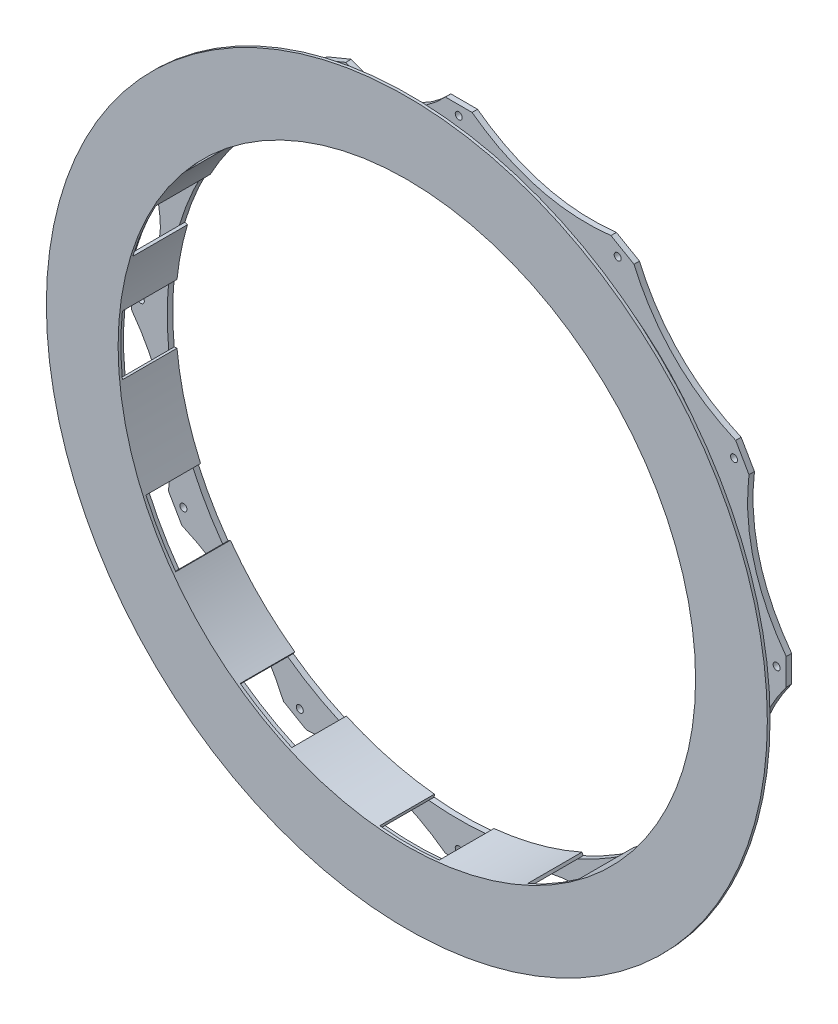
from build123d import *
from build123d.topology import SkipClean

# Parameters (mm, degrees)
SKETCH4_R           = 169.4688
SKETCH4_R_2         = 2.032
BOSS_EXTRUDE1_DEPTH = 3.175
SKETCH5_R           = 169.4688
SKETCH5_R_2         = 2.032
BOSS_EXTRUDE2_DEPTH = 3.175
BOSS_EXTRUDE3_DEPTH = 31.75
SKETCH7_R           = 209.55
SKETCH7_R_2         = 167.8432
BOSS_EXTRUDE4_DEPTH = 1.5875


with BuildPart() as part:
    # Sketch4 → Boss-Extrude1 (new body)
    with BuildSketch(Plane.XY):
        with BuildLine():
            Line((-7.735342369, 190.342886598), (7.735342369, 190.342886598))
            add(Edge.make_bspline(
                [(7.735342369, 190.342886598), (43.849986057, 163.650375876), (88.472440301, 168.709446408)],
                knots=[0, 0, 0, 1, 1, 1], degree=2))
            Line((88.472440301, 168.709446408), (101.870446297, 160.974104039))
            add(Edge.make_bspline(
                [(101.870446297, 160.974104039), (119.800389819, 119.800389819), (160.974104039, 101.870446297)],
                knots=[0, 0, 0, 1, 1, 1], degree=2))
            Line((160.974104039, 101.870446297), (168.709446408, 88.472440301))
            add(Edge.make_bspline(
                [(168.709446408, 88.472440301), (163.650375876, 43.849986057), (190.342886598, 7.735342369)],
                knots=[0, 0, 0, 1, 1, 1], degree=2))
            Line((190.342886598, 7.735342369), (190.342886598, -7.735342369))
            add(Edge.make_bspline(
                [(190.342886598, -7.735342369), (163.650375876, -43.849986057), (168.709446408, -88.472440301)],
                knots=[0, 0, 0, 1, 1, 1], degree=2))
            Line((168.709446408, -88.472440301), (160.974104039, -101.870446297))
            add(Edge.make_bspline(
                [(160.974104039, -101.870446297), (119.800389819, -119.800389819), (101.870446297, -160.974104039)],
                knots=[0, 0, 0, 1, 1, 1], degree=2))
            Line((101.870446297, -160.974104039), (88.472440301, -168.709446408))
            add(Edge.make_bspline(
                [(88.472440301, -168.709446408), (43.849986057, -163.650375876), (7.735342369, -190.342886598)],
                knots=[0, 0, 0, 1, 1, 1], degree=2))
            Line((7.735342369, -190.342886598), (-7.735342369, -190.342886598))
            add(Edge.make_bspline(
                [(-7.735342369, -190.342886598), (-43.849986057, -163.650375876), (-88.472440301, -168.709446408)],
                knots=[0, 0, 0, 1, 1, 1], degree=2))
            Line((-88.472440301, -168.709446408), (-101.870446297, -160.974104039))
            add(Edge.make_bspline(
                [(-101.870446297, -160.974104039), (-119.800389819, -119.800389819), (-160.974104039, -101.870446297)],
                knots=[0, 0, 0, 1, 1, 1], degree=2))
            Line((-160.974104039, -101.870446297), (-168.709446408, -88.472440301))
            add(Edge.make_bspline(
                [(-168.709446408, -88.472440301), (-163.650375876, -43.849986057), (-190.342886598, -7.735342369)],
                knots=[0, 0, 0, 1, 1, 1], degree=2))
            Line((-190.342886598, -7.735342369), (-190.342886598, 7.735342369))
            add(Edge.make_bspline(
                [(-190.342886598, 7.735342369), (-163.877360858, 32.597233808), (-178.814084455, 65.694544678)],
                knots=[0, 0, 0, 1, 1, 1], degree=2))
            Line((-178.814084455, 65.694544678), (-172.893709719, 79.987593661))
            add(Edge.make_bspline(
                [(-172.893709719, 79.987593661), (-138.92851822, 92.829068072), (-140.062458908, 129.12303282)],
                knots=[0, 0, 0, 1, 1, 1], degree=2))
            Line((-140.062458908, 129.12303282), (-129.12303282, 140.062458908))
            add(Edge.make_bspline(
                [(-129.12303282, 140.062458908), (-92.829068072, 138.92851822), (-79.987593661, 172.893709719)],
                knots=[0, 0, 0, 1, 1, 1], degree=2))
            Line((-79.987593661, 172.893709719), (-65.694544678, 178.814084455))
            add(Edge.make_bspline(
                [(-65.694544678, 178.814084455), (-32.597233808, 163.877360858), (-7.735342369, 190.342886598)],
                knots=[0, 0, 0, 1, 1, 1], degree=2))
        make_face()
        Circle(SKETCH4_R, mode=Mode.SUBTRACT)
        with Locations((0, 184.785)):
            Circle(SKETCH4_R_2, mode=Mode.SUBTRACT)
        with Locations((-160.028504238, -92.3925)):
            Circle(SKETCH4_R_2, mode=Mode.SUBTRACT)
        with Locations((-92.3925, -160.028504238)):
            Circle(SKETCH4_R_2, mode=Mode.SUBTRACT)
        with Locations((0, -184.785)):
            Circle(SKETCH4_R_2, mode=Mode.SUBTRACT)
        with Locations((92.3925, -160.028504238)):
            Circle(SKETCH4_R_2, mode=Mode.SUBTRACT)
        with Locations((160.028504238, -92.3925)):
            Circle(SKETCH4_R_2, mode=Mode.SUBTRACT)
        with Locations((184.785, 0)):
            Circle(SKETCH4_R_2, mode=Mode.SUBTRACT)
        with Locations((160.028504238, 92.3925)):
            Circle(SKETCH4_R_2, mode=Mode.SUBTRACT)
        with Locations((92.3925, 160.028504238)):
            Circle(SKETCH4_R_2, mode=Mode.SUBTRACT)
        with Locations((-70.71415805, 170.719079415)):
            Circle(SKETCH4_R_2, mode=Mode.SUBTRACT)
        with Locations((-130.662726562, 130.662726562)):
            Circle(SKETCH4_R_2, mode=Mode.SUBTRACT)
        with Locations((-170.719079415, 70.71415805)):
            Circle(SKETCH4_R_2, mode=Mode.SUBTRACT)
        with Locations((-184.785, 0)):
            Circle(SKETCH4_R_2, mode=Mode.SUBTRACT)
    extrude(amount=BOSS_EXTRUDE1_DEPTH)



with BuildPart() as body_2:
    # Sketch5 → Boss-Extrude2 (new body)
    with BuildSketch(Plane.XY.offset(28.575)):
        with BuildLine():
            Line((-129.12303282, 140.062458908), (-140.062458906, 129.123032763))
            add(Edge.make_bspline(
                [(-140.062458906, 129.123032763), (-138.928518246, 92.829068053), (-172.893709736, 79.987593655)],
                knots=[0, 0, 0, 1, 1, 1], degree=2))
            Line((-172.893709736, 79.987593655), (-178.814084432, 65.694544626))
            add(Edge.make_bspline(
                [(-178.814084432, 65.694544626), (-163.877360879, 32.597233789), (-190.342886598, 7.735342369)],
                knots=[0, 0, 0, 1, 1, 1], degree=2))
            Line((-190.342886598, 7.735342369), (-190.342886584, -7.735342387))
            add(Edge.make_bspline(
                [(-190.342886584, -7.735342387), (-163.650375877, -43.849986068), (-168.709446408, -88.472440301)],
                knots=[0, 0, 0, 1, 1, 1], degree=2))
            Line((-168.709446408, -88.472440301), (-160.974104018, -101.870446307))
            add(Edge.make_bspline(
                [(-160.974104018, -101.870446307), (-119.800389814, -119.800389829), (-101.870446297, -160.974104039)],
                knots=[0, 0, 0, 1, 1, 1], degree=2))
            Line((-101.870446297, -160.974104039), (-88.472440278, -168.709446405))
            add(Edge.make_bspline(
                [(-88.472440278, -168.709446405), (-43.849986048, -163.650375882), (-7.735342369, -190.342886598)],
                knots=[0, 0, 0, 1, 1, 1], degree=2))
            Line((-7.735342369, -190.342886598), (7.735342387, -190.342886584))
            add(Edge.make_bspline(
                [(7.735342387, -190.342886584), (43.849986068, -163.650375877), (88.472440301, -168.709446408)],
                knots=[0, 0, 0, 1, 1, 1], degree=2))
            Line((88.472440301, -168.709446408), (101.870446307, -160.974104018))
            add(Edge.make_bspline(
                [(101.870446307, -160.974104018), (119.800389829, -119.800389814), (160.974104039, -101.870446297)],
                knots=[0, 0, 0, 1, 1, 1], degree=2))
            Line((160.974104039, -101.870446297), (168.709446405, -88.472440278))
            add(Edge.make_bspline(
                [(168.709446405, -88.472440278), (163.650375882, -43.849986048), (190.342886598, -7.735342369)],
                knots=[0, 0, 0, 1, 1, 1], degree=2))
            Line((190.342886598, -7.735342369), (190.342886584, 7.735342387))
            add(Edge.make_bspline(
                [(190.342886584, 7.735342387), (163.650375877, 43.849986068), (168.709446408, 88.472440301)],
                knots=[0, 0, 0, 1, 1, 1], degree=2))
            Line((168.709446408, 88.472440301), (160.974104018, 101.870446307))
            add(Edge.make_bspline(
                [(160.974104018, 101.870446307), (119.800389814, 119.800389829), (101.870446297, 160.974104039)],
                knots=[0, 0, 0, 1, 1, 1], degree=2))
            Line((101.870446297, 160.974104039), (88.472440278, 168.709446405))
            add(Edge.make_bspline(
                [(88.472440278, 168.709446405), (43.849986048, 163.650375882), (7.735342369, 190.342886598)],
                knots=[0, 0, 0, 1, 1, 1], degree=2))
            Line((7.735342369, 190.342886598), (-7.735342408, 190.342886556))
            add(Edge.make_bspline(
                [(-7.735342408, 190.342886556), (-32.597233834, 163.87736087), (-65.694544678, 178.814084455)],
                knots=[0, 0, 0, 1, 1, 1], degree=2))
            Line((-65.694544678, 178.814084455), (-79.987593681, 172.893709665))
            add(Edge.make_bspline(
                [(-79.987593681, 172.893709665), (-92.829068101, 138.92851822), (-129.12303282, 140.062458908)],
                knots=[0, 0, 0, 1, 1, 1], degree=2))
        make_face()
        Circle(SKETCH5_R, mode=Mode.SUBTRACT)
        with Locations((0, 184.785)):
            Circle(SKETCH5_R_2, mode=Mode.SUBTRACT)
        with Locations((-160.028504238, -92.3925)):
            Circle(SKETCH5_R_2, mode=Mode.SUBTRACT)
        with Locations((-70.71415805, 170.719079415)):
            Circle(SKETCH5_R_2, mode=Mode.SUBTRACT)
        with Locations((92.3925, -160.028504238)):
            Circle(SKETCH5_R_2, mode=Mode.SUBTRACT)
        with Locations((0, -184.785)):
            Circle(SKETCH5_R_2, mode=Mode.SUBTRACT)
        with Locations((-92.3925, -160.028504238)):
            Circle(SKETCH5_R_2, mode=Mode.SUBTRACT)
        with Locations((184.785, 0)):
            Circle(SKETCH5_R_2, mode=Mode.SUBTRACT)
        with Locations((160.028504238, -92.3925)):
            Circle(SKETCH5_R_2, mode=Mode.SUBTRACT)
        with Locations((92.3925, 160.028504238)):
            Circle(SKETCH5_R_2, mode=Mode.SUBTRACT)
        with Locations((160.028504238, 92.3925)):
            Circle(SKETCH5_R_2, mode=Mode.SUBTRACT)
        with Locations((-184.785, 0)):
            Circle(SKETCH5_R_2, mode=Mode.SUBTRACT)
        with Locations((-170.719079415, 70.71415805)):
            Circle(SKETCH5_R_2, mode=Mode.SUBTRACT)
        with Locations((-130.662726562, 130.662726562)):
            Circle(SKETCH5_R_2, mode=Mode.SUBTRACT)
    extrude(amount=BOSS_EXTRUDE2_DEPTH)


with BuildPart() as part_1:
    add(part.part)

    add(body_2.part)  # Boss-Extrude3 merges body 2
    # Sketch6 → Boss-Extrude3 (add, through all)
    with BuildSketch(Plane.XY.offset(31.75)):
        with BuildLine():
            Line((17.471010309, 168.565826822), (17.30342268, 166.948888435))
            ThreePointArc((17.30342268, 166.948888435), (43.441016751, 162.124081647), (68.489240604, 153.233689859))
            Line((68.489240604, 153.233689859), (69.152574653, 154.717793392))
            ThreePointArc((69.152574653, 154.717793392), (43.861752991, 163.69429067), (17.471010309, 168.565826822))
        make_face()
        with BuildLine():
            Line((99.413252169, 137.246783083), (98.459647831, 135.930267178))
            ThreePointArc((98.459647831, 135.930267178), (118.683064896, 118.683064896), (135.930267178, 98.459647831))
            Line((135.930267178, 98.459647831), (137.246783083, 99.413252169))
            ThreePointArc((137.246783083, 99.413252169), (119.83253768, 119.83253768), (99.413252169, 137.246783083))
        make_face()
        with BuildLine():
            Line((154.717793392, 69.152574653), (153.233689859, 68.489240604))
            ThreePointArc((153.233689859, 68.489240604), (162.124081647, 43.441016751), (166.948888435, 17.30342268))
            Line((166.948888435, 17.30342268), (168.565826822, 17.471010309))
            ThreePointArc((168.565826822, 17.471010309), (163.69429067, 43.861752991), (154.717793392, 69.152574653))
        make_face()
        with BuildLine():
            Line((168.565826822, -17.471010309), (166.948888435, -17.30342268))
            ThreePointArc((166.948888435, -17.30342268), (162.124081647, -43.441016751), (153.233689859, -68.489240604))
            Line((153.233689859, -68.489240604), (154.717793392, -69.152574653))
            ThreePointArc((154.717793392, -69.152574653), (163.69429067, -43.861752991), (168.565826822, -17.471010309))
        make_face()
        with BuildLine():
            Line((137.246783083, -99.413252169), (135.930267178, -98.459647831))
            ThreePointArc((135.930267178, -98.459647831), (118.683064896, -118.683064896), (98.459647831, -135.930267178))
            Line((98.459647831, -135.930267178), (99.413252169, -137.246783083))
            ThreePointArc((99.413252169, -137.246783083), (119.83253768, -119.83253768), (137.246783083, -99.413252169))
        make_face()
        with BuildLine():
            Line((69.152574653, -154.717793392), (68.489240604, -153.233689859))
            ThreePointArc((68.489240604, -153.233689859), (43.441016751, -162.124081647), (17.30342268, -166.948888435))
            Line((17.30342268, -166.948888435), (17.471010309, -168.565826822))
            ThreePointArc((17.471010309, -168.565826822), (43.861752991, -163.69429067), (69.152574653, -154.717793392))
        make_face()
        with BuildLine():
            Line((-17.471010309, -168.565826822), (-17.30342268, -166.948888435))
            ThreePointArc((-17.30342268, -166.948888435), (-43.441016751, -162.124081647), (-68.489240604, -153.233689859))
            Line((-68.489240604, -153.233689859), (-69.152574653, -154.717793392))
            ThreePointArc((-69.152574653, -154.717793392), (-43.861752991, -163.69429067), (-17.471010309, -168.565826822))
        make_face()
        with BuildLine():
            Line((-99.413252169, -137.246783083), (-98.459647831, -135.930267178))
            ThreePointArc((-98.459647831, -135.930267178), (-118.683064896, -118.683064896), (-135.930267178, -98.459647831))
            Line((-135.930267178, -98.459647831), (-137.246783083, -99.413252169))
            ThreePointArc((-137.246783083, -99.413252169), (-119.83253768, -119.83253768), (-99.413252169, -137.246783083))
        make_face()
        with BuildLine():
            Line((-154.717793392, -69.152574653), (-153.233689859, -68.489240604))
            ThreePointArc((-153.233689859, -68.489240604), (-162.124081647, -43.441016751), (-166.948888435, -17.30342268))
            Line((-166.948888435, -17.30342268), (-168.565826822, -17.471010309))
            ThreePointArc((-168.565826822, -17.471010309), (-163.69429067, -43.861752991), (-154.717793392, -69.152574653))
        make_face()
        with BuildLine():
            Line((-47.902295599, 160.862394184), (-48.366240351, 162.420383474))
            ThreePointArc((-48.366240351, 162.420383474), (-33.061722764, 166.212504528), (-17.471010309, 168.565826822))
            Line((-17.471010309, 168.565826822), (-17.30342268, 166.948888435))
            ThreePointArc((-17.30342268, 166.948888435), (-32.744583936, 164.618139976), (-47.902295599, 160.862394184))
        make_face()
        with BuildLine():
            Line((-105.815323609, 130.286058639), (-106.840169358, 131.547909086))
            ThreePointArc((-106.840169358, 131.547909086), (-94.151820706, 140.908157433), (-80.648458025, 149.04865109))
            Line((-80.648458025, 149.04865109), (-79.874851713, 147.618927818))
            ThreePointArc((-79.874851713, 147.618927818), (-93.248685735, 139.556520432), (-105.815323609, 130.286058639))
        make_face()
        with BuildLine():
            Line((-147.618927818, 79.874851713), (-149.04865109, 80.648458025))
            ThreePointArc((-149.04865109, 80.648458025), (-140.908157433, 94.151820706), (-131.547909086, 106.840169358))
            Line((-131.547909086, 106.840169358), (-130.286058639, 105.815323609))
            ThreePointArc((-130.286058639, 105.815323609), (-139.556520432, 93.248685735), (-147.618927818, 79.874851713))
        make_face()
        with BuildLine():
            Line((-166.948888435, 17.30342268), (-168.565826822, 17.471010309))
            ThreePointArc((-168.565826822, 17.471010309), (-166.212504528, 33.061722764), (-162.420383474, 48.366240351))
            Line((-162.420383474, 48.366240351), (-160.862394184, 47.902295599))
            ThreePointArc((-160.862394184, 47.902295599), (-164.618139976, 32.744583936), (-166.948888435, 17.30342268))
        make_face()
    extrude(amount=-BOSS_EXTRUDE3_DEPTH)

    # Sketch7 → Boss-Extrude4 (add)
    with SkipClean():  # the faces are left unmerged after this step: merging them gives an invalid solid
        with BuildSketch(Plane.XY.offset(31.75)):
            Circle(SKETCH7_R)
            Circle(SKETCH7_R_2, mode=Mode.SUBTRACT)
        extrude(amount=BOSS_EXTRUDE4_DEPTH)


solid = part_1.part
